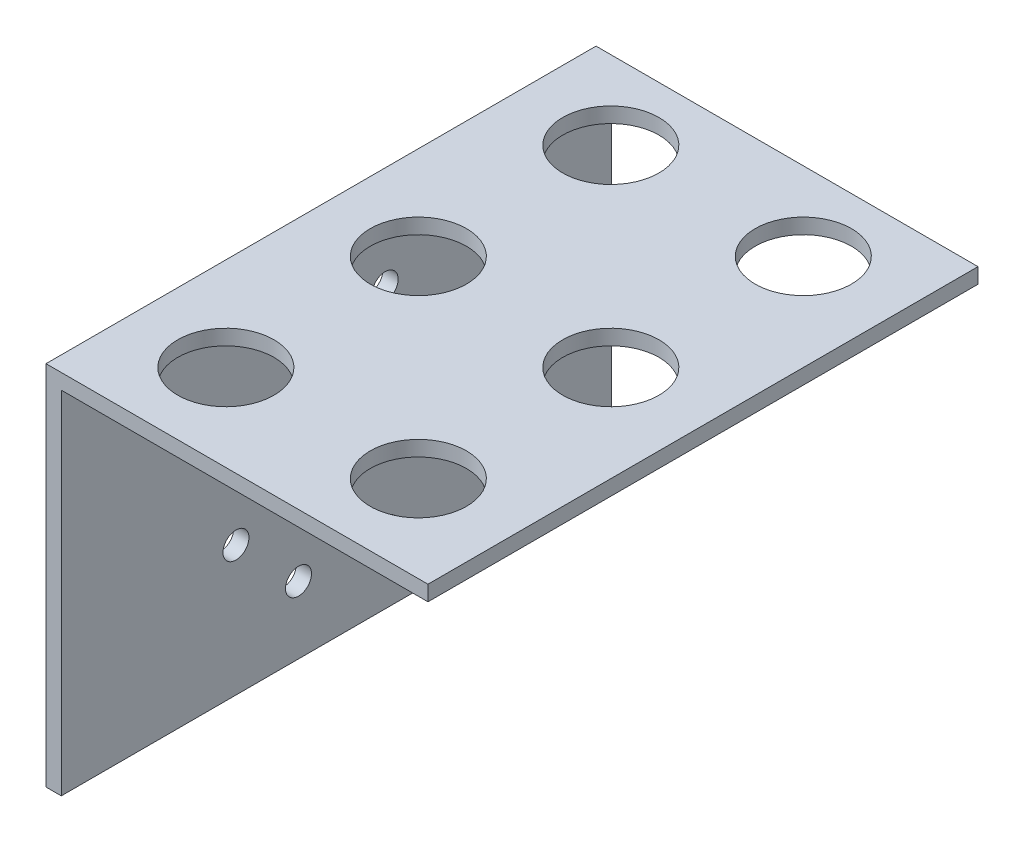
from build123d import *

# Parameters (mm, degrees)
BOSS_EXTRUDE1_DEPTH = 57.15
SKETCH3_R           = 1.35
CUT_EXTRUDE1_DEPTH  = 2.5875
SKETCH2_R           = 5
CUT_EXTRUDE2_DEPTH  = 2.5875


with BuildPart() as part:
    # Sketch1 → Boss-Extrude1 (new body)
    with BuildSketch(Plane.XY):
        Polygon((-25.651653512, -10.718726646), (-24.064153512, -10.718726646), (-24.064153512, 25.793773354), (14.035846488, 25.793773354), (14.035846488, 27.381273354), (-24.064153512, 27.381273354), (-25.651653512, 27.381273354), align=None)
    extrude(amount=BOSS_EXTRUDE1_DEPTH)

    # Sketch3 → Cut-Extrude1 (cut, through all)
    with BuildSketch(Plane(origin=(-24.064153512, 0, 0), x_dir=(0, 0, -1), z_dir=(1, 0, 0))):
        with Locations((-32.5, 18.281273354)):
            Circle(SKETCH3_R)
        with Locations((-23.5, 18.281273354)):
            Circle(SKETCH3_R)
        with Locations((-17, 11.781273354)):
            Circle(SKETCH3_R)
        with Locations((-17, 2.781273354)):
            Circle(SKETCH3_R)
        with Locations((-23.5, -3.718726646)):
            Circle(SKETCH3_R)
        with Locations((-32.5, -3.718726646)):
            Circle(SKETCH3_R)
        with Locations((-39, 2.781273354)):
            Circle(SKETCH3_R)
        with Locations((-39, 11.781273354)):
            Circle(SKETCH3_R)
    extrude(amount=-CUT_EXTRUDE1_DEPTH, mode=Mode.SUBTRACT)

    # Sketch2 → Cut-Extrude2 (cut, through all)
    with BuildSketch(Plane.XZ.offset(-25.793773354)):
        with Locations((4.035846488, 48.15)):
            Circle(SKETCH2_R)
        with Locations((4.035846488, 28.15)):
            Circle(SKETCH2_R)
        with Locations((4.035846488, 8.15)):
            Circle(SKETCH2_R)
        with Locations((-15.964153512, 48.15)):
            Circle(SKETCH2_R)
        with Locations((-15.964153512, 28.15)):
            Circle(SKETCH2_R)
        with Locations((-15.964153512, 8.15)):
            Circle(SKETCH2_R)
    extrude(amount=-CUT_EXTRUDE2_DEPTH, mode=Mode.SUBTRACT)


solid = part.part
